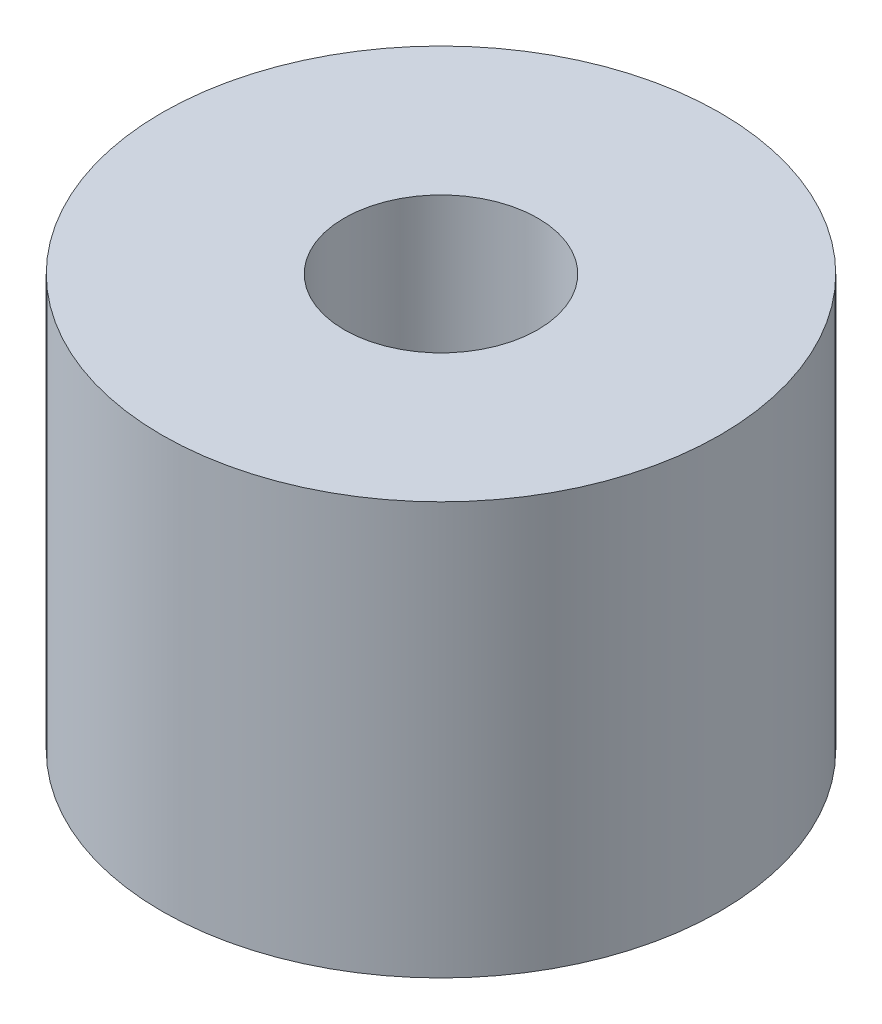
from build123d import *

# Parameters (mm, degrees)
CROQUIS1_R              = 7.5
CROQUIS1_R_2            = 2.6
SALIENTE_EXTRUIR1_DEPTH = 11.08


with BuildPart() as part:
    # Croquis1 → Saliente-Extruir1 (new body)
    with BuildSketch(Plane(origin=(0, 0, 0), x_dir=(1, 0, 0), z_dir=(0, 1, 0))):
        Circle(CROQUIS1_R)
        Circle(CROQUIS1_R_2, mode=Mode.SUBTRACT)
    extrude(amount=SALIENTE_EXTRUIR1_DEPTH)


solid = part.part
